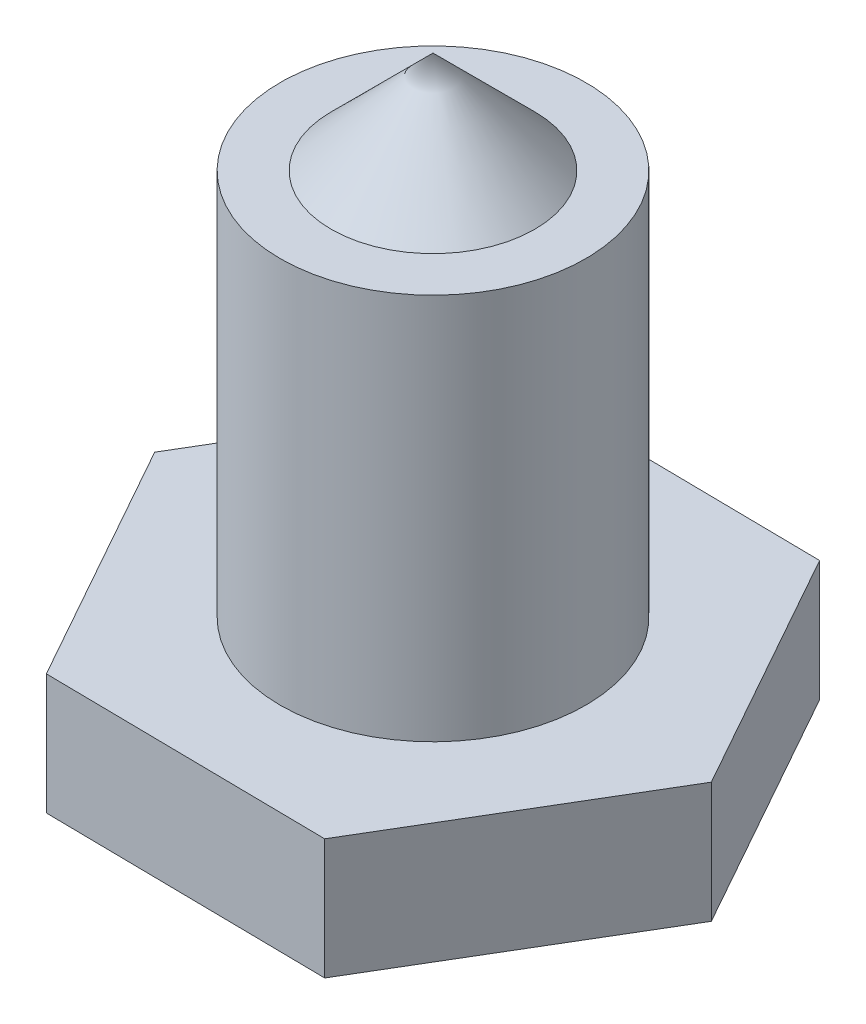
from build123d import *

# Parameters (mm, degrees)
BOSS_EXTRUDE1_DEPTH = 4.7
SKETCH2_R           = 5.953125
BOSS_EXTRUDE2_DEPTH = 15.08125


with BuildPart() as part:
    # Sketch1 → Boss-Extrude1 (new body)
    with BuildSketch(Plane(origin=(0, 0, 0), x_dir=(1, 0, 0), z_dir=(0, 1, 0))):
        Polygon((5.624451566, 9.451615977), (-5.37311376, 9.596725927), (-10.997565326, 0.14510995), (-5.624451566, -9.451615977), (5.37311376, -9.596725927), (10.997565326, -0.14510995), align=None)
    extrude(amount=BOSS_EXTRUDE1_DEPTH)

    # Sketch2 → Boss-Extrude2 (add)
    with BuildSketch(Plane(origin=(0, 4.7, 0), x_dir=(1, 0, 0), z_dir=(0, 1, 0))):
        Circle(SKETCH2_R)
    extrude(amount=BOSS_EXTRUDE2_DEPTH)

    # Sketch4 → Revolve1 (revolve)
    with BuildSketch(Plane(origin=(0, 0, 0), x_dir=(0, 0, -1), z_dir=(1, 0, 0))):
        Polygon((0, 19.78125), (0, 23.75), (3.96875, 19.78125), align=None)
    revolve(axis=Axis((0, 19.78125, 0), (0, 1, 0)))


solid = part.part
